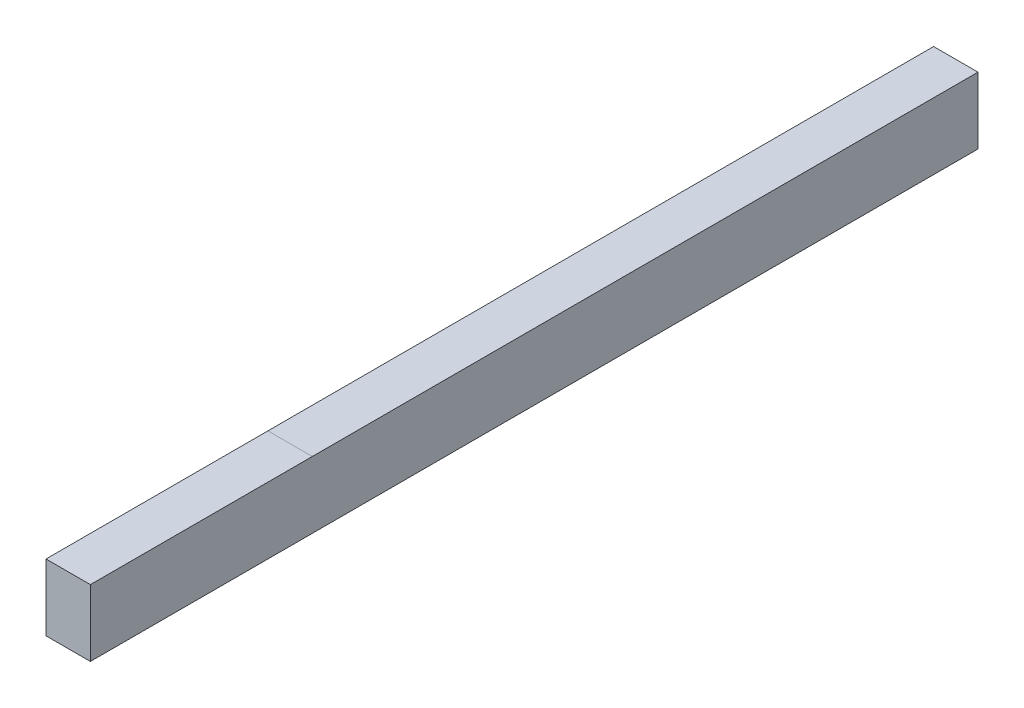
from build123d import *

# Parameters (mm, degrees)
SZKIC1_W                    = 10
SZKIC1_H                    = 15
DODANIE_WYCI_GNI_CIE1_DEPTH = 200


with BuildPart() as part:
    # Szkic1 → Dodanie-wyciągnięcie1 (new body)
    with BuildSketch(Plane.XY):
        with Locations((5, 7.5)):
            Rectangle(SZKIC1_W, SZKIC1_H)
    extrude(amount=DODANIE_WYCI_GNI_CIE1_DEPTH)


solid = part.part
